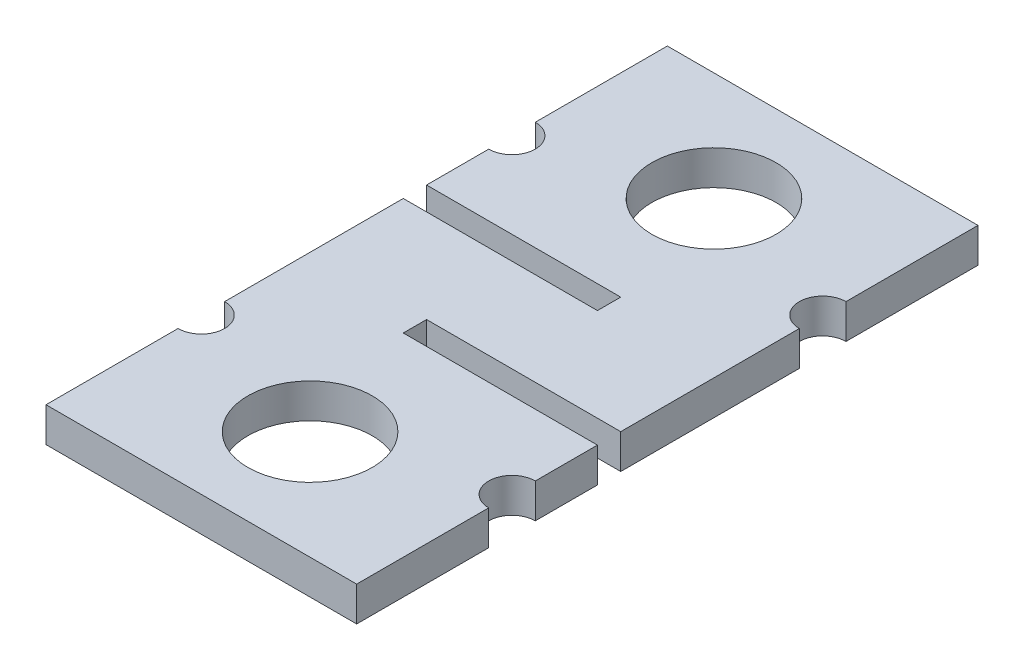
from build123d import *

# Parameters (mm, degrees)
CROQUIS1_R              = 8
SALIENTE_EXTRUIR1_DEPTH = 4.45


with BuildPart() as part:
    # Croquis1 → Saliente-Extruir1 (new body)
    with BuildSketch(Plane(origin=(0, 0, 0), x_dir=(1, 0, 0), z_dir=(0, 1, 0))):
        with BuildLine():
            Line((-20, -41.25), (20, -41.25))
            Line((20, -41.25), (20, -24.25))
            ThreePointArc((20, -24.25), (17, -21.25), (20, -18.25))
            Line((20, -18.25), (20, -10.25))
            Line((20, -10.25), (-5, -10.25))
            Line((-5, -10.25), (-5, -7.25))
            Line((-5, -7.25), (20, -7.25))
            Line((20, -7.25), (20, 15.75))
            ThreePointArc((20, 15.75), (17, 18.75), (20, 21.75))
            Line((20, 21.75), (20, 38.75))
            Line((20, 38.75), (-20, 38.75))
            Line((-20, 38.75), (-20, 21.75))
            ThreePointArc((-20, 21.75), (-17, 18.75), (-20, 15.75))
            Line((-20, 15.75), (-20, 7.75))
            Line((-20, 7.75), (5, 7.75))
            Line((5, 7.75), (5, 4.75))
            Line((5, 4.75), (-20, 4.75))
            Line((-20, 4.75), (-20, -18.25))
            ThreePointArc((-20, -18.25), (-17, -21.25), (-20, -24.25))
            Line((-20, -24.25), (-20, -41.25))
        make_face()
        with Locations((0, -27.25)):
            Circle(CROQUIS1_R, mode=Mode.SUBTRACT)
        with Locations((0, 24.75)):
            Circle(CROQUIS1_R, mode=Mode.SUBTRACT)
    extrude(amount=SALIENTE_EXTRUIR1_DEPTH)


solid = part.part
